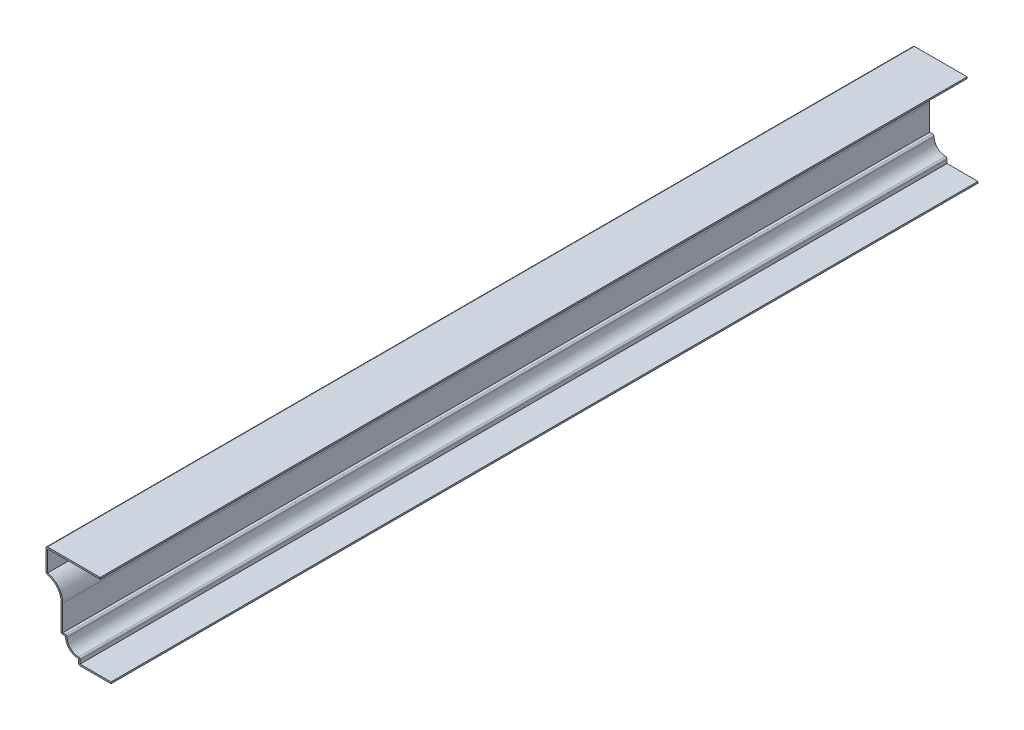
from build123d import *

# Parameters (mm, degrees)
EXTRUDE_THIN1_DEPTH = 635
FILLET1_R           = 1.143


with BuildPart() as part:
    # Sketch1 → Extrude-Thin1 (new body)
    with BuildSketch(Plane.XY):
        with BuildLine():
            Line((0, 0), (-23.8125, 0))
            Line((-23.8125, 0), (-23.8125, 3.96875))
            ThreePointArc((-23.8125, 3.96875), (-30.547692, 6.758558), (-33.3375, 13.49375))
            Line((-33.3375, 13.49375), (-36.5125, 13.49375))
            Line((-36.5125, 13.49375), (-36.5125, 33.437109))
            ThreePointArc((-36.5125, 33.437109), (-39.6875, 41.83737), (-47.625, 46.0375))
            Line((-47.625, 46.0375), (-47.625, 63.5))
            Line((-47.625, 63.5), (-7.9375, 63.5))
            Line((-7.9375, 63.5), (-7.9375, 62.357))
            Line((-7.9375, 62.357), (-46.482, 62.357))
            Line((-46.482, 62.357), (-46.482, 47.008145))
            ThreePointArc((-46.482, 47.008145), (-38.502062, 42.207239), (-35.3695, 33.437109))
            Line((-35.3695, 33.437109), (-35.3695, 14.63675))
            Line((-35.3695, 14.63675), (-32.116202, 14.63675))
            ThreePointArc((-32.116202, 14.63675), (-29.739469, 7.566781), (-22.6695, 5.190048))
            Line((-22.6695, 5.190048), (-22.6695, 1.143))
            Line((-22.6695, 1.143), (0, 1.143))
            Line((0, 1.143), (0, 0))
        make_face()
    extrude(amount=-EXTRUDE_THIN1_DEPTH)

    # Fillet1
    fillet1_edges = [part.edges().sort_by_distance(p)[0] for p in [
        (-32.116202, 14.63675, -317.5),
        (-22.6695, 5.190048, -317.5),
        (-23.8125, 0, -317.5),
        (-36.5125, 13.49375, -317.5),
        (-47.625, 46.0375, -317.5),
        (-47.625, 63.5, -317.5),
    ]]
    fillet(fillet1_edges, radius=FILLET1_R)


solid = part.part
